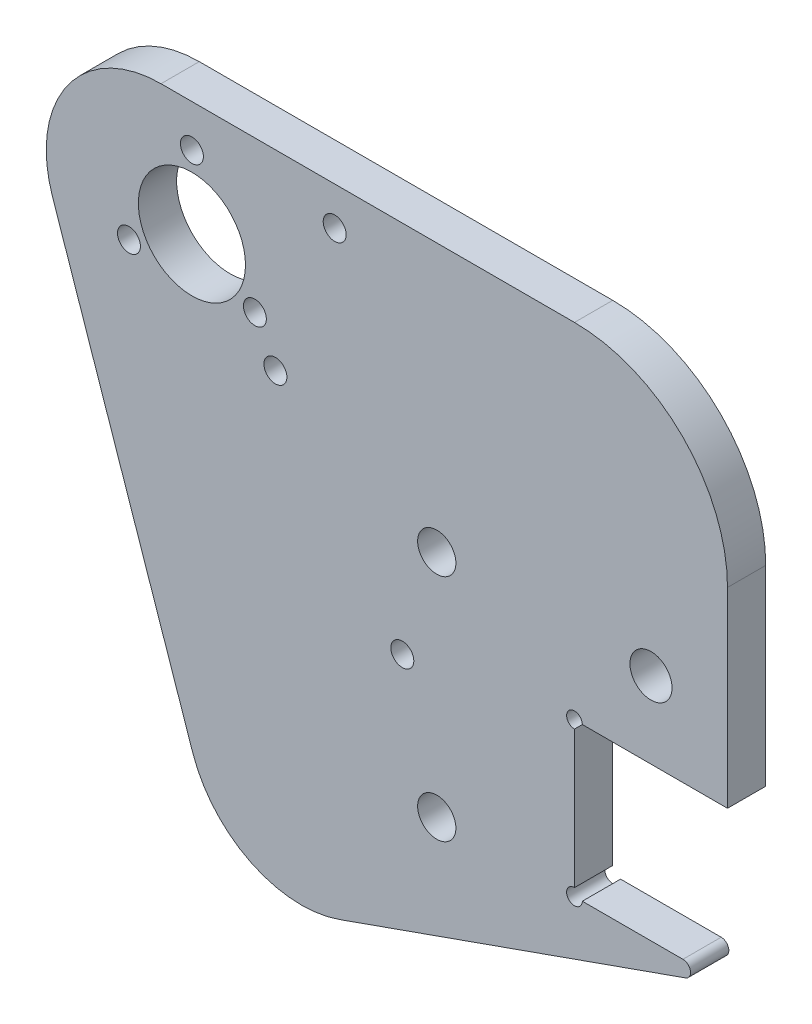
from build123d import *

# Parameters (mm, degrees)
SKETCH_1_R          = 7
SKETCH_1_R_2        = 1.5
SKETCH_1_R_3        = 2.5
EXTRUDE_1_DEPTH     = 5
FILLET_1_R          = 1
SKETCH_2_R          = 1.5
SKETCH_2_R_2        = 2.75
CUT_EXTRUDE_1_DEPTH = 10
SKETCH_3_R          = 1.5
CUT_EXTRUDE_2_DEPTH = 10
SKETCH_4_R          = 1.025
CUT_EXTRUDE_3_DEPTH = 30


with BuildPart() as part:
    # 草图1 → 凸台-拉伸1 (new body)
    with BuildSketch(Plane.XY):
        with BuildLine():
            Line((70, -30), (70, -5))
            ThreePointArc((70, -5), (64.142135624, 9.142135624), (50, 15))
            Line((50, 15), (-4.038673683, 15))
            ThreePointArc((-4.038673683, 15), (-16.237067712, 8.729214347), (-18.236326506, -4.840108917))
            Line((-18.236326506, -4.840108917), (0.10369211, -58.637496855))
            ThreePointArc((0.10369211, -58.637496855), (7.762372735, -67.297085809), (19.305024689, -67.938222033))
            Line((19.305024689, -67.938222033), (70, -50))
            Line((70, -50), (50, -50))
            Line((50, -50), (50, -30))
            Line((50, -30), (70, -30))
        make_face()
        Circle(SKETCH_1_R, mode=Mode.SUBTRACT)
        with Locations((0, 9.5)):
            Circle(SKETCH_1_R_2, mode=Mode.SUBTRACT)
        with Locations((8.227241336, -4.75)):
            Circle(SKETCH_1_R_2, mode=Mode.SUBTRACT)
        with Locations((-8.227241336, -4.75)):
            Circle(SKETCH_1_R_2, mode=Mode.SUBTRACT)
        with Locations((32, -50)):
            Circle(SKETCH_1_R_3, mode=Mode.SUBTRACT)
        with Locations((32, -20)):
            Circle(SKETCH_1_R_3, mode=Mode.SUBTRACT)
    extrude(amount=EXTRUDE_1_DEPTH)

    # 圆角1
    fillet_1_edges = [part.edges().sort_by_distance(p)[0] for p in [
        (70, -50, 2.5),
    ]]
    fillet(fillet_1_edges, radius=FILLET_1_R)

    # 草图2 → 切除-拉伸1 (cut)
    with BuildSketch(Plane.XY.offset(5)):
        with Locations((27.5, -33.82)):
            Circle(SKETCH_2_R)
        with Locations((18.66, 10)):
            Circle(SKETCH_2_R)
        with Locations((60, -20)):
            Circle(SKETCH_2_R_2)
    extrude(amount=-CUT_EXTRUDE_1_DEPTH, mode=Mode.SUBTRACT)

    # 草图3 → 切除-拉伸2 (cut)
    with BuildSketch(Plane.XY.offset(5)):
        with Locations((10.914424012, -10)):
            Circle(SKETCH_3_R)
    extrude(amount=-CUT_EXTRUDE_2_DEPTH, mode=Mode.SUBTRACT)

    # 草图4 → 切除-拉伸3 (cut, symmetric)
    with BuildSketch(Plane(origin=(0, 0, 0), x_dir=(-1, 0, 0), z_dir=(0, 0, -1))):
        with Locations((-50, -50)):
            Circle(SKETCH_4_R)
        with Locations((-50, -30)):
            Circle(SKETCH_4_R)
    extrude(amount=CUT_EXTRUDE_3_DEPTH, both=True, mode=Mode.SUBTRACT)


solid = part.part
